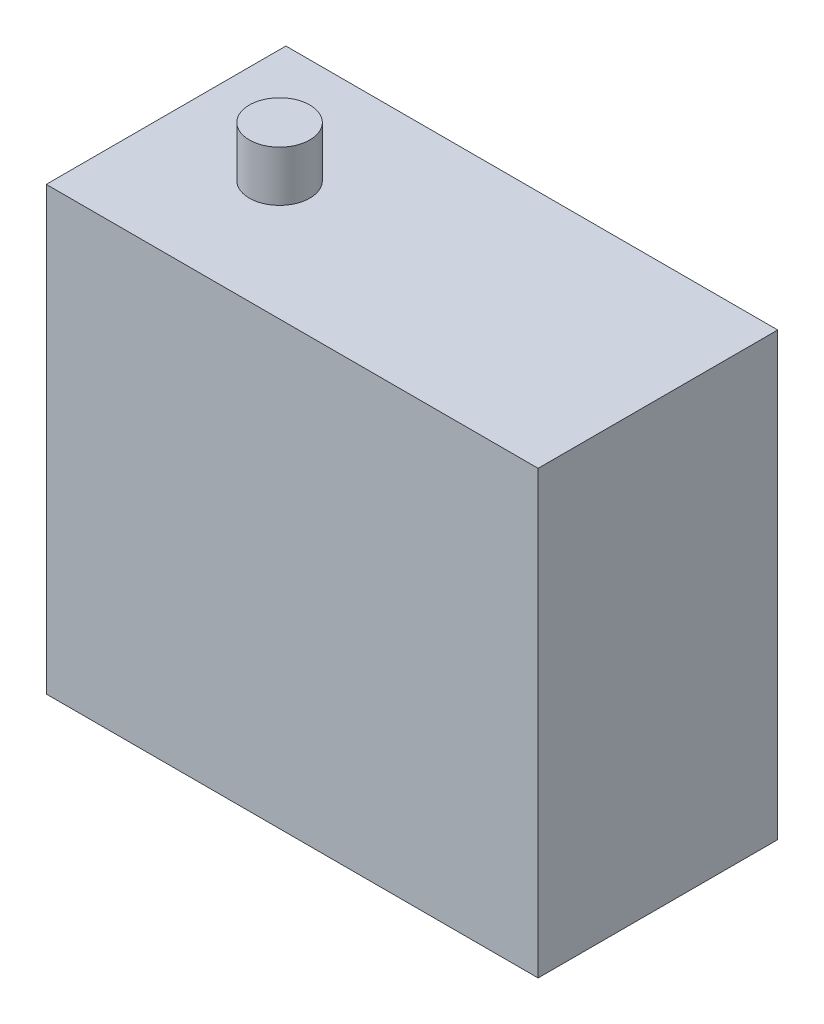
from build123d import *

# Parameters (mm, degrees)
SKETCH1_W           = 39
SKETCH1_H           = 19
BOSS_EXTRUDE1_DEPTH = 35
SKETCH2_R           = 2.4
BOSS_EXTRUDE2_DEPTH = 4


with BuildPart() as part:
    # Sketch1 → Boss-Extrude1 (new body)
    with BuildSketch(Plane(origin=(0, 0, 0), x_dir=(1, 0, 0), z_dir=(0, 1, 0))):
        Rectangle(SKETCH1_W, SKETCH1_H)
    extrude(amount=BOSS_EXTRUDE1_DEPTH)

    # Sketch2 → Boss-Extrude2 (add)
    with BuildSketch(Plane(origin=(0, 35, 0), x_dir=(1, 0, 0), z_dir=(0, 1, 0))):
        with Locations((-10.5, 0)):
            Circle(SKETCH2_R)
    extrude(amount=BOSS_EXTRUDE2_DEPTH)


solid = part.part
